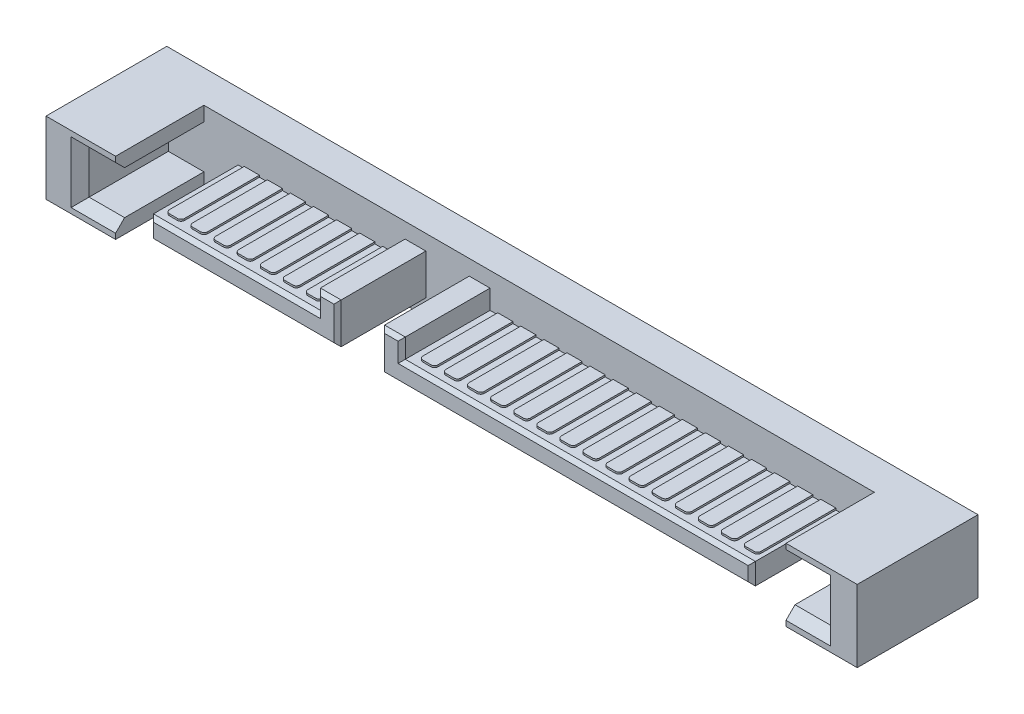
from build123d import *

# Parameters (mm, degrees)
SKETCH1_W           = 45
SKETCH1_H           = 6.7
BOSS_EXTRUDE1_DEPTH = 4
SKETCH2_W           = 1.97
SKETCH2_H           = 2.4
CUT_EXTRUDE1_DEPTH  = 4.9
BOSS_EXTRUDE2_DEPTH = 0.1
CHAMFER1_SIZE       = 0.5
CHAMFER2_SIZE       = 0.2


with BuildPart() as part:
    # Sketch1 → Boss-Extrude1 (new body)
    with BuildSketch(Plane(origin=(0, 0, 0), x_dir=(1, 0, 0), z_dir=(0, 1, 0))):
        Rectangle(SKETCH1_W, SKETCH1_H)
    extrude(amount=BOSS_EXTRUDE1_DEPTH)

    # Sketch2 → Cut-Extrude1 (cut)
    with BuildSketch(Plane.XY.offset(3.35)):
        with Locations((-19.625, 2)):
            Rectangle(SKETCH2_W, SKETCH2_H)
        Polygon((18.55, 4), (-18.64, 4), (-18.64, 3.2), (-18.64, 0.8), (-18.64, 0), (18.55, 0), (18.55, 0.8), (18.55, 3.2), align=None)
        Polygon((-16.74, 0.9), (-16.74, 2.08), (-7.48, 2.08), (-7.48, 3.15), (-6.33, 3.15), (-6.33, 0.9), align=None, mode=Mode.SUBTRACT)
        Polygon((16.65, 0.9), (-3.92, 0.9), (-3.92, 3.15), (-2.77, 3.15), (-2.77, 2.08), (16.65, 2.08), align=None, mode=Mode.SUBTRACT)
        with Locations((19.535, 2)):
            Rectangle(SKETCH2_W, SKETCH2_H)
    extrude(amount=-CUT_EXTRUDE1_DEPTH, mode=Mode.SUBTRACT)

    # Sketch3 → Boss-Extrude2 (add)
    with BuildSketch(Plane(origin=(0, 2.08, 0), x_dir=(1, 0, 0), z_dir=(0, 1, 0))):
        with BuildLine():
            Line((-7.88, 1.55), (-8.72, 1.55))
            Line((-8.72, 1.55), (-8.72, -2.6))
            ThreePointArc((-8.72, -2.6), (-8.661421356, -2.741421356), (-8.52, -2.8))
            Line((-8.52, -2.8), (-8.08, -2.8))
            ThreePointArc((-8.08, -2.8), (-7.938578644, -2.741421356), (-7.88, -2.6))
            Line((-7.88, -2.6), (-7.88, 1.55))
        make_face()
        with BuildLine():
            Line((-9.16, 1.55), (-9.16, -2.6))
            ThreePointArc((-9.16, -2.6), (-9.218578644, -2.741421356), (-9.36, -2.8))
            Line((-9.36, -2.8), (-9.8, -2.8))
            ThreePointArc((-9.8, -2.8), (-9.941421356, -2.741421356), (-10, -2.6))
            Line((-10, -2.6), (-10, 1.55))
            Line((-10, 1.55), (-9.16, 1.55))
        make_face()
        with BuildLine():
            Line((-10.44, 1.55), (-10.44, -2.6))
            ThreePointArc((-10.44, -2.6), (-10.498578644, -2.741421356), (-10.64, -2.8))
            Line((-10.64, -2.8), (-11.08, -2.8))
            ThreePointArc((-11.08, -2.8), (-11.221421356, -2.741421356), (-11.28, -2.6))
            Line((-11.28, -2.6), (-11.28, 1.55))
            Line((-11.28, 1.55), (-10.44, 1.55))
        make_face()
        with BuildLine():
            Line((-11.72, 1.55), (-11.72, -2.6))
            ThreePointArc((-11.72, -2.6), (-11.778578644, -2.741421356), (-11.92, -2.8))
            Line((-11.92, -2.8), (-12.36, -2.8))
            ThreePointArc((-12.36, -2.8), (-12.501421356, -2.741421356), (-12.56, -2.6))
            Line((-12.56, -2.6), (-12.56, 1.55))
            Line((-12.56, 1.55), (-11.72, 1.55))
        make_face()
        with BuildLine():
            Line((-13, 1.55), (-13, -2.6))
            ThreePointArc((-13, -2.6), (-13.058578644, -2.741421356), (-13.2, -2.8))
            Line((-13.2, -2.8), (-13.64, -2.8))
            ThreePointArc((-13.64, -2.8), (-13.781421356, -2.741421356), (-13.84, -2.6))
            Line((-13.84, -2.6), (-13.84, 1.55))
            Line((-13.84, 1.55), (-13, 1.55))
        make_face()
        with BuildLine():
            Line((-14.28, 1.55), (-14.28, -2.6))
            ThreePointArc((-14.28, -2.6), (-14.338578644, -2.741421356), (-14.48, -2.8))
            Line((-14.48, -2.8), (-14.92, -2.8))
            ThreePointArc((-14.92, -2.8), (-15.061421356, -2.741421356), (-15.12, -2.6))
            Line((-15.12, -2.6), (-15.12, 1.55))
            Line((-15.12, 1.55), (-14.28, 1.55))
        make_face()
        with BuildLine():
            Line((-15.56, 1.55), (-15.56, -2.6))
            ThreePointArc((-15.56, -2.6), (-15.618578644, -2.741421356), (-15.76, -2.8))
            Line((-15.76, -2.8), (-16.2, -2.8))
            ThreePointArc((-16.2, -2.8), (-16.341421356, -2.741421356), (-16.4, -2.6))
            Line((-16.4, -2.6), (-16.4, 1.55))
            Line((-16.4, 1.55), (-15.56, 1.55))
        make_face()
        with BuildLine():
            Line((-2.34, 1.55), (-1.5, 1.55))
            Line((-1.5, 1.55), (-1.5, -2.6))
            ThreePointArc((-1.5, -2.6), (-1.558578644, -2.741421356), (-1.7, -2.8))
            Line((-1.7, -2.8), (-2.14, -2.8))
            ThreePointArc((-2.14, -2.8), (-2.281421356, -2.741421356), (-2.34, -2.6))
            Line((-2.34, -2.6), (-2.34, 1.55))
        make_face()
        with BuildLine():
            Line((-1.06, 1.55), (-1.06, -2.6))
            ThreePointArc((-1.06, -2.6), (-1.001421356, -2.741421356), (-0.86, -2.8))
            Line((-0.86, -2.8), (-0.42, -2.8))
            ThreePointArc((-0.42, -2.8), (-0.278578644, -2.741421356), (-0.22, -2.6))
            Line((-0.22, -2.6), (-0.22, 1.55))
            Line((-0.22, 1.55), (-1.06, 1.55))
        make_face()
        with BuildLine():
            Line((0.22, 1.55), (0.22, -2.6))
            ThreePointArc((0.22, -2.6), (0.278578644, -2.741421356), (0.42, -2.8))
            Line((0.42, -2.8), (0.86, -2.8))
            ThreePointArc((0.86, -2.8), (1.001421356, -2.741421356), (1.06, -2.6))
            Line((1.06, -2.6), (1.06, 1.55))
            Line((1.06, 1.55), (0.22, 1.55))
        make_face()
        with BuildLine():
            Line((1.5, 1.55), (1.5, -2.6))
            ThreePointArc((1.5, -2.6), (1.558578644, -2.741421356), (1.7, -2.8))
            Line((1.7, -2.8), (2.14, -2.8))
            ThreePointArc((2.14, -2.8), (2.281421356, -2.741421356), (2.34, -2.6))
            Line((2.34, -2.6), (2.34, 1.55))
            Line((2.34, 1.55), (1.5, 1.55))
        make_face()
        with BuildLine():
            Line((2.78, 1.55), (2.78, -2.6))
            ThreePointArc((2.78, -2.6), (2.838578644, -2.741421356), (2.98, -2.8))
            Line((2.98, -2.8), (3.42, -2.8))
            ThreePointArc((3.42, -2.8), (3.561421356, -2.741421356), (3.62, -2.6))
            Line((3.62, -2.6), (3.62, 1.55))
            Line((3.62, 1.55), (2.78, 1.55))
        make_face()
        with BuildLine():
            Line((4.06, 1.55), (4.06, -2.6))
            ThreePointArc((4.06, -2.6), (4.118578644, -2.741421356), (4.26, -2.8))
            Line((4.26, -2.8), (4.7, -2.8))
            ThreePointArc((4.7, -2.8), (4.841421356, -2.741421356), (4.9, -2.6))
            Line((4.9, -2.6), (4.9, 1.55))
            Line((4.9, 1.55), (4.06, 1.55))
        make_face()
        with BuildLine():
            Line((5.34, 1.55), (5.34, -2.6))
            ThreePointArc((5.34, -2.6), (5.398578644, -2.741421356), (5.54, -2.8))
            Line((5.54, -2.8), (5.98, -2.8))
            ThreePointArc((5.98, -2.8), (6.121421356, -2.741421356), (6.18, -2.6))
            Line((6.18, -2.6), (6.18, 1.55))
            Line((6.18, 1.55), (5.34, 1.55))
        make_face()
        with BuildLine():
            Line((6.62, 1.55), (6.62, -2.6))
            ThreePointArc((6.62, -2.6), (6.678578644, -2.741421356), (6.82, -2.8))
            Line((6.82, -2.8), (7.26, -2.8))
            ThreePointArc((7.26, -2.8), (7.401421356, -2.741421356), (7.46, -2.6))
            Line((7.46, -2.6), (7.46, 1.55))
            Line((7.46, 1.55), (6.62, 1.55))
        make_face()
        with BuildLine():
            Line((7.9, 1.55), (7.9, -2.6))
            ThreePointArc((7.9, -2.6), (7.958578644, -2.741421356), (8.1, -2.8))
            Line((8.1, -2.8), (8.54, -2.8))
            ThreePointArc((8.54, -2.8), (8.681421356, -2.741421356), (8.74, -2.6))
            Line((8.74, -2.6), (8.74, 1.55))
            Line((8.74, 1.55), (7.9, 1.55))
        make_face()
        with BuildLine():
            Line((9.18, 1.55), (9.18, -2.6))
            ThreePointArc((9.18, -2.6), (9.238578644, -2.741421356), (9.38, -2.8))
            Line((9.38, -2.8), (9.82, -2.8))
            ThreePointArc((9.82, -2.8), (9.961421356, -2.741421356), (10.02, -2.6))
            Line((10.02, -2.6), (10.02, 1.55))
            Line((10.02, 1.55), (9.18, 1.55))
        make_face()
        with BuildLine():
            Line((10.46, 1.55), (10.46, -2.6))
            ThreePointArc((10.46, -2.6), (10.518578644, -2.741421356), (10.66, -2.8))
            Line((10.66, -2.8), (11.1, -2.8))
            ThreePointArc((11.1, -2.8), (11.241421356, -2.741421356), (11.3, -2.6))
            Line((11.3, -2.6), (11.3, 1.55))
            Line((11.3, 1.55), (10.46, 1.55))
        make_face()
        with BuildLine():
            Line((11.74, 1.55), (11.74, -2.6))
            ThreePointArc((11.74, -2.6), (11.798578644, -2.741421356), (11.94, -2.8))
            Line((11.94, -2.8), (12.38, -2.8))
            ThreePointArc((12.38, -2.8), (12.521421356, -2.741421356), (12.58, -2.6))
            Line((12.58, -2.6), (12.58, 1.55))
            Line((12.58, 1.55), (11.74, 1.55))
        make_face()
        with BuildLine():
            Line((13.02, 1.55), (13.02, -2.6))
            ThreePointArc((13.02, -2.6), (13.078578644, -2.741421356), (13.22, -2.8))
            Line((13.22, -2.8), (13.66, -2.8))
            ThreePointArc((13.66, -2.8), (13.801421356, -2.741421356), (13.86, -2.6))
            Line((13.86, -2.6), (13.86, 1.55))
            Line((13.86, 1.55), (13.02, 1.55))
        make_face()
        with BuildLine():
            Line((14.3, 1.55), (14.3, -2.6))
            ThreePointArc((14.3, -2.6), (14.358578644, -2.741421356), (14.5, -2.8))
            Line((14.5, -2.8), (14.94, -2.8))
            ThreePointArc((14.94, -2.8), (15.081421356, -2.741421356), (15.14, -2.6))
            Line((15.14, -2.6), (15.14, 1.55))
            Line((15.14, 1.55), (14.3, 1.55))
        make_face()
        with BuildLine():
            Line((15.58, 1.55), (15.58, -2.6))
            ThreePointArc((15.58, -2.6), (15.638578644, -2.741421356), (15.78, -2.8))
            Line((15.78, -2.8), (16.22, -2.8))
            ThreePointArc((16.22, -2.8), (16.361421356, -2.741421356), (16.42, -2.6))
            Line((16.42, -2.6), (16.42, 1.55))
            Line((16.42, 1.55), (15.58, 1.55))
        make_face()
    extrude(amount=BOSS_EXTRUDE2_DEPTH)

    # Chamfer1
    chamfer1_edges = [part.edges().sort_by_distance(p)[0] for p in [
        (-20.61, 2, 3.35),
        (19.535, 3.2, 3.35),
        (-19.625, 0.8, 3.35),
        (19.535, 0.8, 3.35),
        (20.52, 2, 3.35),
        (-19.625, 3.2, 3.35),
    ]]
    chamfer(chamfer1_edges, length=CHAMFER1_SIZE)

    # Chamfer2
    chamfer2_edges = [part.edges().sort_by_distance(p)[0] for p in [
        (-12.11, 2.08, 3.35),
        (-16.74, 1.49, 3.35),
        (-11.535, 0.9, 3.35),
        (-6.33, 2.025, 3.35),
        (-6.905, 3.15, 3.35),
        (-3.92, 2.025, 3.35),
        (6.365, 0.9, 3.35),
        (16.65, 1.49, 3.35),
        (6.94, 2.08, 3.35),
        (-2.77, 2.615, 3.35),
        (-3.345, 3.15, 3.35),
        (-7.48, 2.615, 3.35),
    ]]
    chamfer(chamfer2_edges, length=CHAMFER2_SIZE)


solid = part.part
